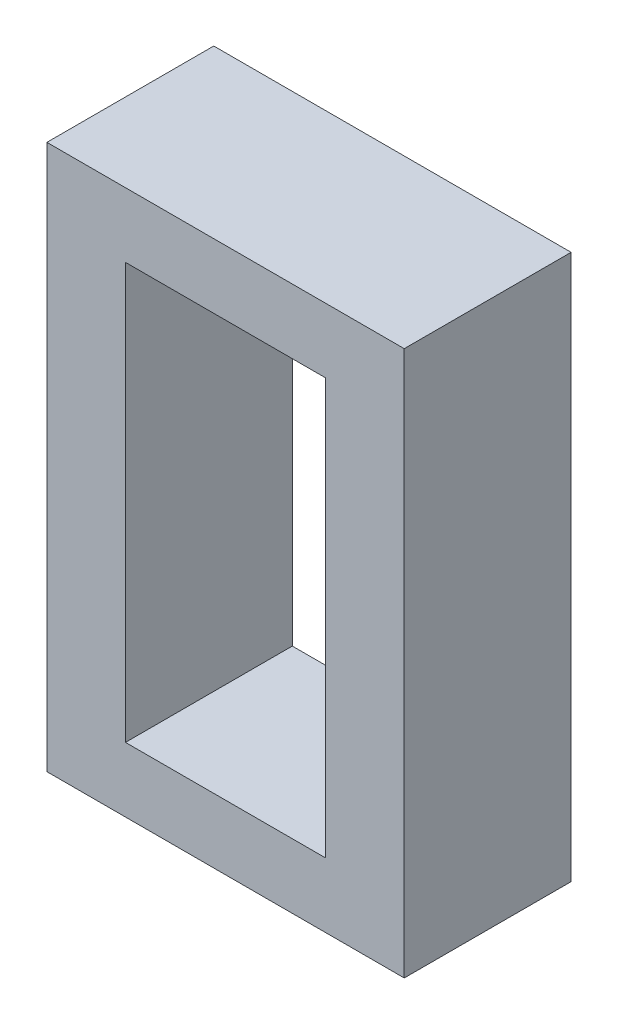
from build123d import *

# Parameters (mm, degrees)
SKETCH3_W           = 25.7
SKETCH3_H           = 39.2
SKETCH3_W_2         = 14.4
SKETCH3_H_2         = 29.9
BOSS_EXTRUDE2_DEPTH = 12


with BuildPart() as part:
    # Sketch3 → Boss-Extrude2 (new body)
    with BuildSketch(Plane.XY):
        with Locations((12.85, 19.6)):
            Rectangle(SKETCH3_W, SKETCH3_H)
        with Locations((12.85, 19.6)):
            Rectangle(SKETCH3_W_2, SKETCH3_H_2, mode=Mode.SUBTRACT)
    extrude(amount=BOSS_EXTRUDE2_DEPTH)


solid = part.part
